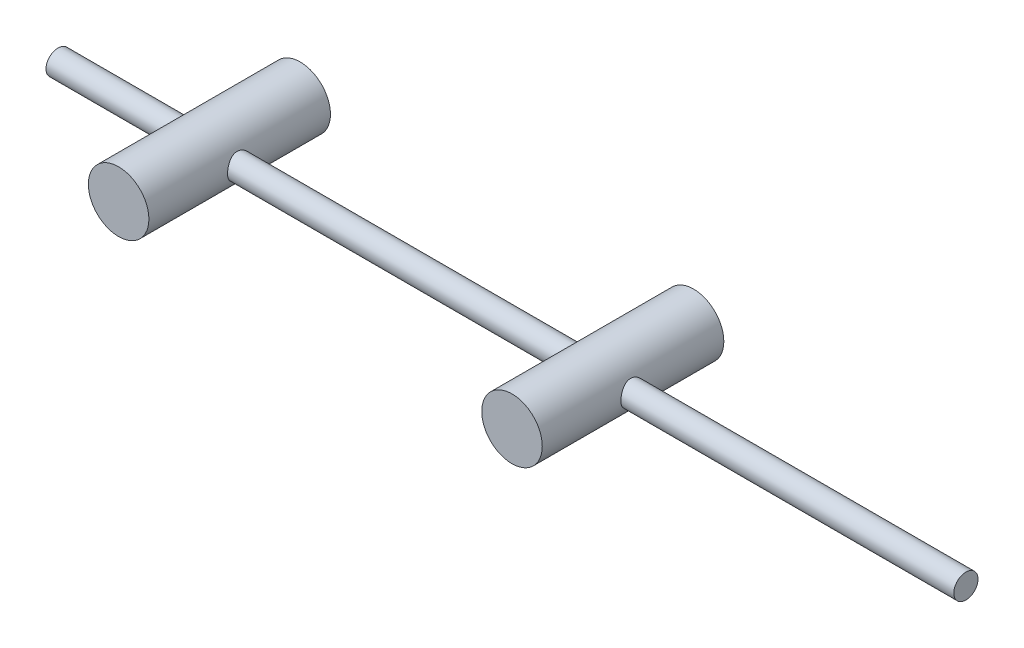
from build123d import *

# Parameters (mm, degrees)
ESQUISSE1_W      = 150
ESQUISSE1_H      = 2
ESQUISSE2_R      = 5
EXTRUSION1_DEPTH = 15


with BuildPart() as part:
    # Esquisse1 → Révolution1 (revolve)
    with BuildSketch(Plane.XY, mode=Mode.PRIVATE) as r_volution1_sk:
        with Locations((75, 1)):
            Rectangle(ESQUISSE1_W, ESQUISSE1_H)
    revolve(r_volution1_sk.sketch.rotate(Axis((0, 0, 0), (1, 0, 0)), 90), axis=Axis((0, 0, 0), (1, 0, 0)))  # turned: the seam where the file's is

    # Esquisse2 → Extrusion1 (add, symmetric)
    with BuildSketch(Plane.XY):
        with Locations((90, 0)):
            Circle(ESQUISSE2_R)
        with Locations((25, 0)):
            Circle(ESQUISSE2_R)
    extrude(amount=EXTRUSION1_DEPTH, both=True)


solid = part.part
